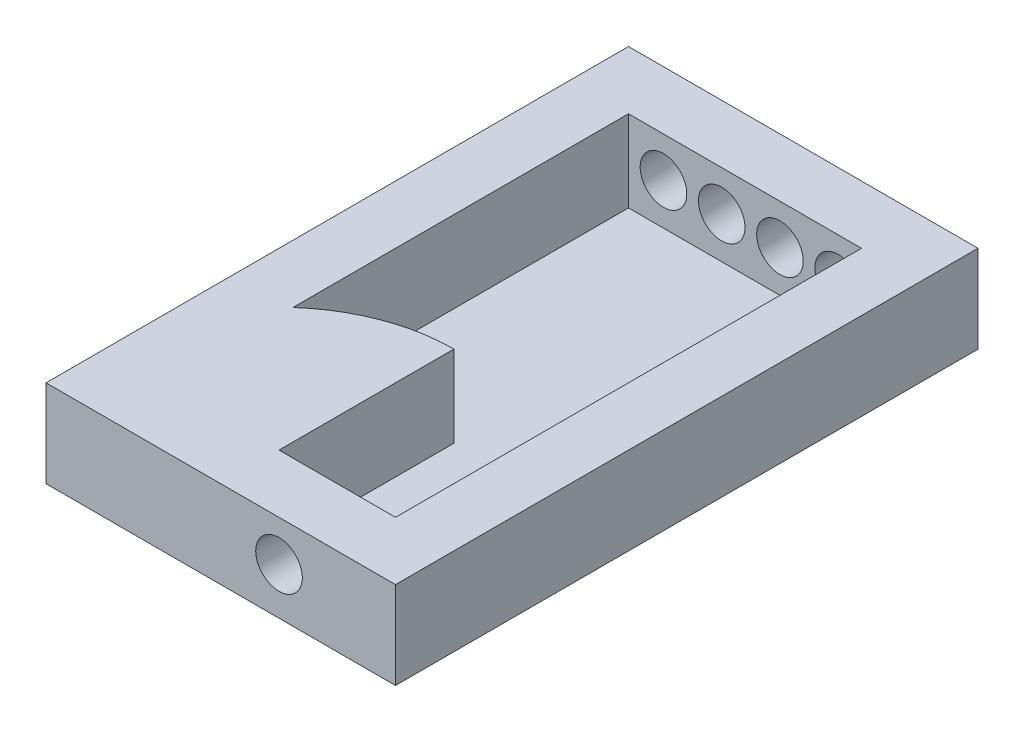
from build123d import *

# Parameters (mm, degrees)
CROQUIS1_W              = 60
CROQUIS1_H              = 100
SALIENTE_EXTRUIR3_DEPTH = 15
CROQUIS2_W              = 40
CROQUIS2_H              = 80
CORTAR_EXTRUIR1_DEPTH   = 14
SALIENTE_EXTRUIR4_DEPTH = 14
CROQUIS4_R              = 4
CORTAR_EXTRUIR2_DEPTH   = 10
CROQUIS5_R              = 4
CORTAR_EXTRUIR3_DEPTH   = 11
CROQUIS7_R              = 5
CORTAR_EXTRUIR5_DEPTH   = 28


with BuildPart() as part:
    # Croquis1 → Saliente-Extruir3 (new body)
    with BuildSketch(Plane(origin=(0, 0, 0), x_dir=(1, 0, 0), z_dir=(0, 1, 0))):
        with Locations((-30, 50)):
            Rectangle(CROQUIS1_W, CROQUIS1_H)
    extrude(amount=SALIENTE_EXTRUIR3_DEPTH)

    # Croquis2 → Cortar-Extruir1 (cut)
    with BuildSketch(Plane(origin=(0, 15, 0), x_dir=(1, 0, 0), z_dir=(0, 1, 0))):
        with Locations((-30, 50)):
            Rectangle(CROQUIS2_W, CROQUIS2_H)
    extrude(amount=-CORTAR_EXTRUIR1_DEPTH, mode=Mode.SUBTRACT)

    # Croquis3 → Saliente-Extruir4 (add)
    with BuildSketch(Plane(origin=(0, 1, 0), x_dir=(1, 0, 0), z_dir=(0, 1, 0))):
        with BuildLine():
            Line((-50, 10), (-30, 10))
            Line((-30, 10), (-30, 40.028839229))
            ThreePointArc((-30, 40.028839229), (-40.702908507, 38.056709268), (-50, 32.399356809))
            Line((-50, 32.399356809), (-50, 10))
        make_face()
    extrude(amount=SALIENTE_EXTRUIR4_DEPTH)

    # Croquis4 → Cortar-Extruir2 (cut)
    with BuildSketch(Plane(origin=(0, 0, -100), x_dir=(-1, 0, 0), z_dir=(0, 0, -1))):
        with Locations((14, 8.093468363)):
            Circle(CROQUIS4_R)
        with Locations((24, 8.093468363)):
            Circle(CROQUIS4_R)
        with Locations((34, 8.093468363)):
            Circle(CROQUIS4_R)
        with Locations((44, 8.093468363)):
            Circle(CROQUIS4_R)
    extrude(amount=-CORTAR_EXTRUIR2_DEPTH, mode=Mode.SUBTRACT)

    # Croquis5 → Cortar-Extruir3 (cut)
    with BuildSketch(Plane(origin=(0, 0, -10), x_dir=(-1, 0, 0), z_dir=(0, 0, -1))):
        with Locations((20, 8)):
            Circle(CROQUIS5_R)
    extrude(amount=-CORTAR_EXTRUIR3_DEPTH, mode=Mode.SUBTRACT)

    # Croquis7 → Cortar-Extruir5 (cut)
    with BuildSketch(Plane.ZY.offset(60)):
        with Locations((-22.972155743, 7.895487944)):
            Circle(CROQUIS7_R)
    extrude(amount=-CORTAR_EXTRUIR5_DEPTH, mode=Mode.SUBTRACT)


solid = part.part
